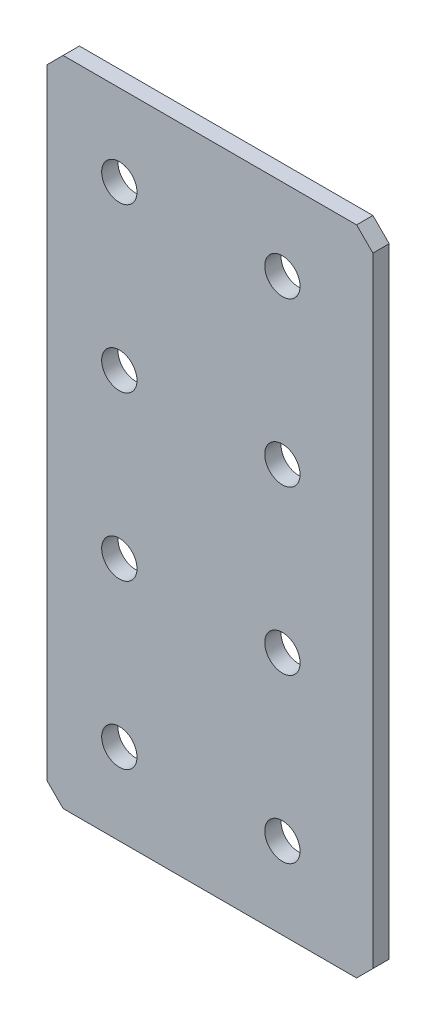
from build123d import *

# Parameters (mm, degrees)
SKETCH1_W           = 60
SKETCH1_H           = 120
SKETCH1_R           = 3.25
BOSS_EXTRUDE1_DEPTH = 3
CHAMFER1_SIZE       = 3


with BuildPart() as part:
    # Sketch1 → Boss-Extrude1 (new body)
    with BuildSketch(Plane.XY):
        with Locations((12.372881356, -8.156527448)):
            Rectangle(SKETCH1_W, SKETCH1_H)
        with Locations((-4.281987853, 36.843472552)):
            Circle(SKETCH1_R, mode=Mode.SUBTRACT)
        with Locations((25.718012147, 36.843472552)):
            Circle(SKETCH1_R, mode=Mode.SUBTRACT)
        with Locations((-4.281987853, 6.843472552)):
            Circle(SKETCH1_R, mode=Mode.SUBTRACT)
        with Locations((25.718012147, 6.843472552)):
            Circle(SKETCH1_R, mode=Mode.SUBTRACT)
        with Locations((-4.281987853, -23.156527448)):
            Circle(SKETCH1_R, mode=Mode.SUBTRACT)
        with Locations((25.718012147, -23.156527448)):
            Circle(SKETCH1_R, mode=Mode.SUBTRACT)
        with Locations((-4.281987853, -53.156527448)):
            Circle(SKETCH1_R, mode=Mode.SUBTRACT)
        with Locations((25.718012147, -53.156527448)):
            Circle(SKETCH1_R, mode=Mode.SUBTRACT)
    extrude(amount=BOSS_EXTRUDE1_DEPTH)

    # Chamfer1
    chamfer1_edges = [part.edges().sort_by_distance(p)[0] for p in [
        (-17.627118644, 51.843472552, 1.5),
        (42.372881356, 51.843472552, 1.5),
        (42.372881356, -68.156527448, 1.5),
        (-17.627118644, -68.156527448, 1.5),
    ]]
    chamfer(chamfer1_edges, length=CHAMFER1_SIZE)


solid = part.part
